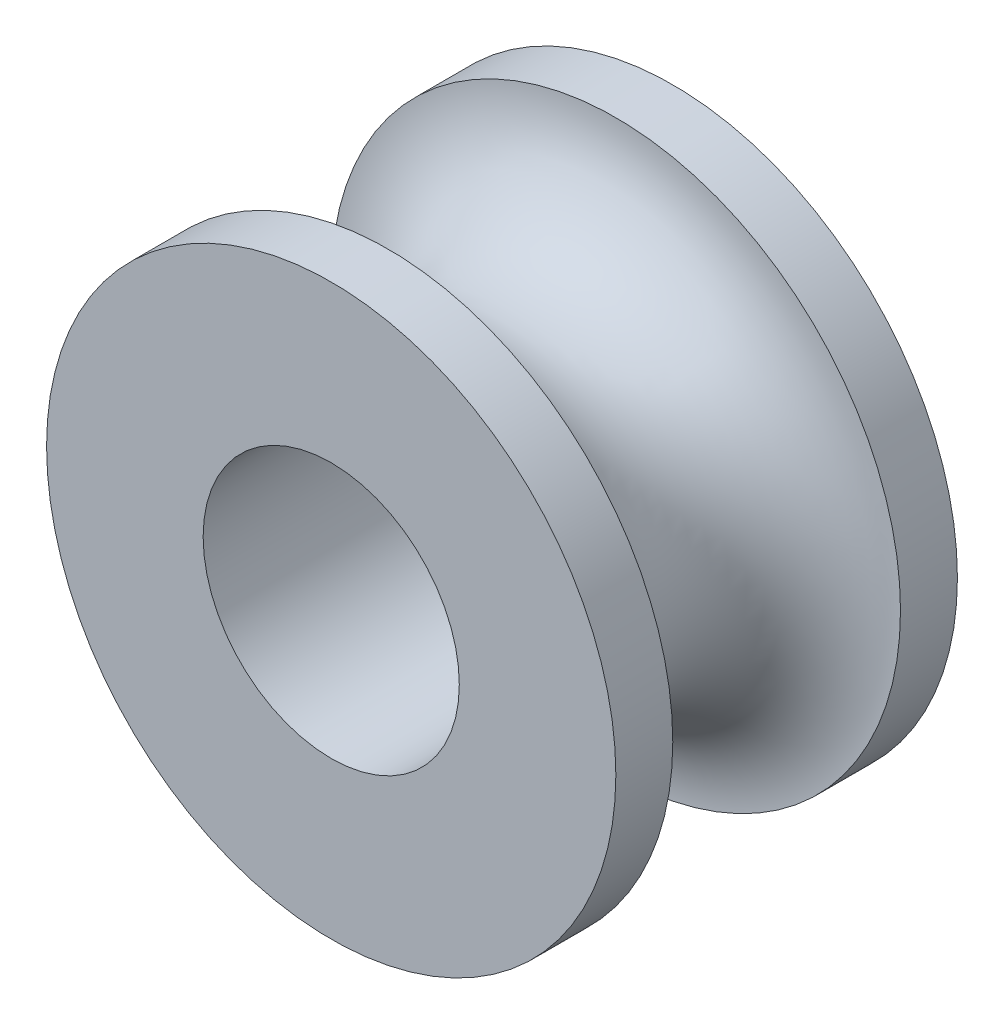
from build123d import *

# Parameters (mm, degrees)
SKETCH1_R           = 5
SKETCH1_R_2         = 2.25
BOSS_EXTRUDE1_DEPTH = 6


with BuildPart() as part:
    # Sketch1 → Boss-Extrude1 (new body)
    with BuildSketch(Plane.XY):
        Circle(SKETCH1_R)
        Circle(SKETCH1_R_2, mode=Mode.SUBTRACT)
    extrude(amount=BOSS_EXTRUDE1_DEPTH)

    # Sketch3 → Cut-Revolve1 (revolve, cut)
    with BuildSketch(Plane(origin=(0, 0, 0), x_dir=(0, 0, -1), z_dir=(1, 0, 0))):
        with BuildLine():
            Line((-5, 5), (-1, 5))
            ThreePointArc((-1, 5), (-3, 3), (-5, 5))
        make_face()
    revolve(axis=Axis((0, 0, 0), (0, 0, 1)), mode=Mode.SUBTRACT)


solid = part.part
